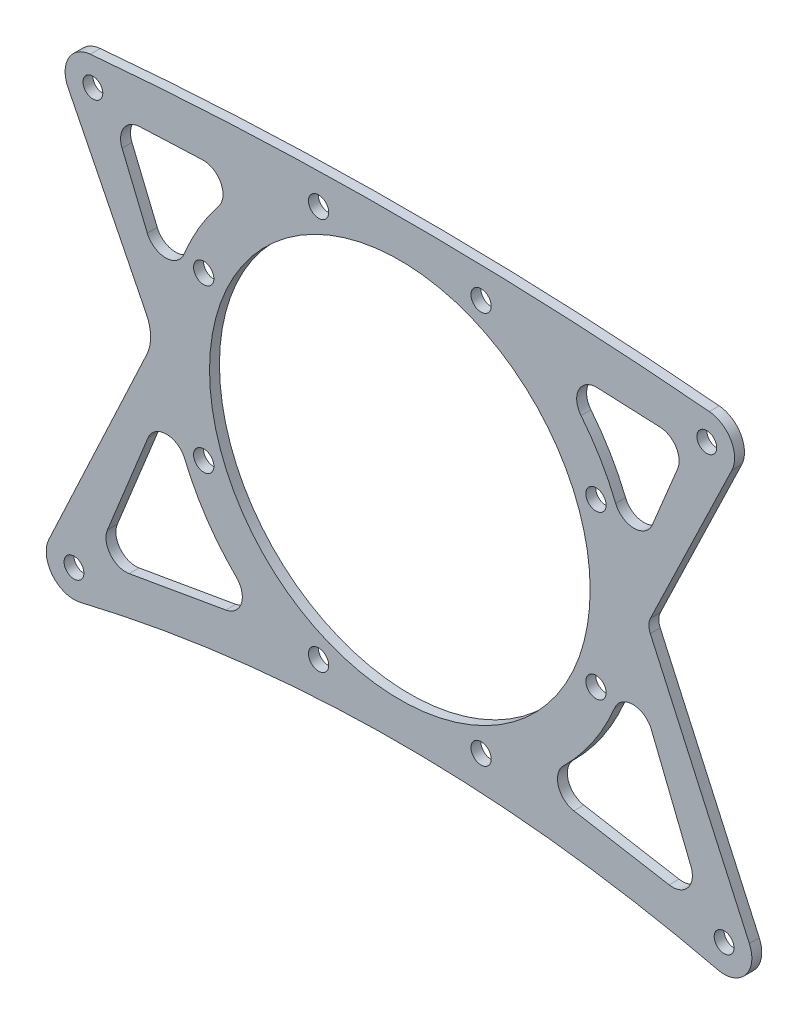
from build123d import *

# Parameters (mm, degrees)
SKETCH5_R           = 3.175
SKETCH5_R_2         = 3.25
SKETCH5_R_3         = 60.96
BOSS_EXTRUDE2_DEPTH = 3.175


with BuildPart() as part:
    # Sketch5 → Boss-Extrude2 (new body)
    with BuildSketch(Plane.XY):
        with BuildLine():
            Line((233.935091571, -114.763518579), (265.665701875, -184.883595476))
            ThreePointArc((265.665701875, -184.883595476), (264.423436425, -194.206670618), (255.505854783, -197.196602259))
            ThreePointArc((255.505854783, -197.196602259), (153.444246818, -185.249846144), (51.403286659, -197.37169633))
            ThreePointArc((51.403286659, -197.37169633), (42.43911219, -194.346602456), (41.276859828, -184.957417917))
            Line((41.276859828, -184.957417917), (72.669263517, -117.915407124))
            ThreePointArc((72.669263517, -117.915407124), (73.866746362, -112.37217505), (72.532031625, -106.860376473))
            Line((72.532031625, -106.860376473), (47.422094343, -56.527870305))
            ThreePointArc((47.422094343, -56.527870305), (47.614528636, -48.22631495), (54.579553655, -43.705111707))
            ThreePointArc((54.579553655, -43.705111707), (153.704366218, -39.249697911), (252.829178781, -43.705111707))
            ThreePointArc((252.829178781, -43.705111707), (259.764657482, -48.173800982), (260.039703094, -56.419672588))
            Line((260.039703094, -56.419672588), (233.987235662, -110.463230544))
            ThreePointArc((233.987235662, -110.463230544), (233.48365469, -112.607584422), (233.935091571, -114.763518579))
        make_face()
        with Locations((49.32793696, -188.727332639)):
            Circle(SKETCH5_R, mode=Mode.SUBTRACT)
        with Locations((55.377109151, -52.559263571)):
            Circle(SKETCH5_R, mode=Mode.SUBTRACT)
        with Locations((252.031623286, -52.559263571)):
            Circle(SKETCH5_R, mode=Mode.SUBTRACT)
        with Locations((90.880558007, -138.272171312)):
            Circle(SKETCH5_R_2, mode=Mode.SUBTRACT)
        with Locations((127.681892817, -175.073506122)):
            Circle(SKETCH5_R_2, mode=Mode.SUBTRACT)
        with Locations((179.726839619, -175.073506122)):
            Circle(SKETCH5_R_2, mode=Mode.SUBTRACT)
        with Locations((216.528174429, -138.272171312)):
            Circle(SKETCH5_R_2, mode=Mode.SUBTRACT)
        with Locations((216.528174429, -86.227224511)):
            Circle(SKETCH5_R_2, mode=Mode.SUBTRACT)
        with Locations((179.726839619, -49.425889701)):
            Circle(SKETCH5_R_2, mode=Mode.SUBTRACT)
        with Locations((127.681892817, -49.425889701)):
            Circle(SKETCH5_R_2, mode=Mode.SUBTRACT)
        with Locations((90.880558007, -86.227224511)):
            Circle(SKETCH5_R_2, mode=Mode.SUBTRACT)
        with Locations((153.704366218, -112.249697911)):
            Circle(SKETCH5_R_3, mode=Mode.SUBTRACT)
        with Locations((257.566369908, -188.548690521)):
            Circle(SKETCH5_R, mode=Mode.SUBTRACT)
        with BuildLine():
            Line((209.461649294, -176.161550354), (239.97260378, -181.443451933))
            ThreePointArc((239.97260378, -181.443451933), (245.991796239, -179.18128426), (246.949420177, -172.822743797))
            Line((246.949420177, -172.822743797), (234.263108846, -141.191675264))
            ThreePointArc((234.263108846, -141.191675264), (228.418953488, -137.205640522), (222.513375511, -141.100094727))
            ThreePointArc((222.513375511, -141.100094727), (215.504437403, -154.056113183), (206.086743584, -165.382660352))
            ThreePointArc((206.086743584, -165.382660352), (204.484912095, -171.801991039), (209.461649294, -176.161550354))
        make_face(mode=Mode.SUBTRACT)
        with BuildLine():
            Line((216.971221053, -55.043652894), (237.085867612, -55.91533392))
            ThreePointArc((237.085867612, -55.91533392), (242.165926056, -58.84665781), (242.677579376, -64.689419522))
            Line((242.677579376, -64.689419522), (234.586463913, -84.223100209))
            ThreePointArc((234.586463913, -84.223100209), (228.697518519, -88.14302122), (222.836263182, -84.181816295))
            ThreePointArc((222.836263182, -84.181816295), (217.987361181, -74.371977351), (211.755754133, -65.37687511))
            ThreePointArc((211.755754133, -65.37687511), (211.027446603, -58.526470596), (216.971221053, -55.043652894))
        make_face(mode=Mode.SUBTRACT)
        with BuildLine():
            Line((67.017865041, -181.584438257), (97.982666146, -176.188564905))
            ThreePointArc((97.982666146, -176.188564905), (102.953981644, -171.82534341), (101.348381832, -165.40866757))
            ThreePointArc((101.348381832, -165.40866757), (91.836215085, -153.955297436), (84.787438766, -140.841344712))
            ThreePointArc((84.787438766, -140.841344712), (78.896402882, -136.924728627), (73.037344469, -140.889021736))
            Line((73.037344469, -140.889021736), (60.042928393, -172.943053933))
            ThreePointArc((60.042928393, -172.943053933), (60.98652829, -179.31704224), (67.017865041, -181.584438257))
        make_face(mode=Mode.SUBTRACT)
        with BuildLine():
            Line((70.322864824, -55.91533392), (90.437511384, -55.043652894))
            ThreePointArc((90.437511384, -55.043652894), (96.381285834, -58.526470596), (95.652978303, -65.37687511))
            ThreePointArc((95.652978303, -65.37687511), (89.421371255, -74.371977351), (84.572469254, -84.181816295))
            ThreePointArc((84.572469254, -84.181816295), (78.711213917, -88.14302122), (72.822268524, -84.223100209))
            Line((72.822268524, -84.223100209), (64.73115306, -64.689419522))
            ThreePointArc((64.73115306, -64.689419522), (65.242806381, -58.84665781), (70.322864824, -55.91533392))
        make_face(mode=Mode.SUBTRACT)
    extrude(amount=BOSS_EXTRUDE2_DEPTH)


solid = part.part
